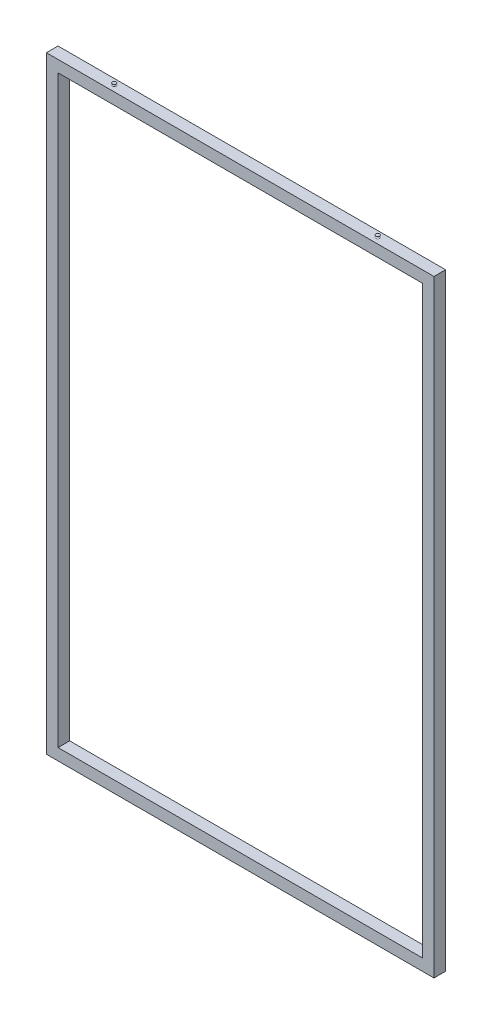
from build123d import *

# Parameters (mm, degrees)
SKETCH1_W           = 1000
SKETCH1_H           = 1567.75
SKETCH1_W_2         = 940
SKETCH1_H_2         = 1507.75
BOSS_EXTRUDE1_DEPTH = 15
SKETCH2_W           = 26
SKETCH2_H           = 26


with BuildPart() as part:
    # Sketch1 → Boss-Extrude1 (new body, symmetric)
    with BuildSketch(Plane.XY):
        Rectangle(SKETCH1_W, SKETCH1_H)
        Rectangle(SKETCH1_W_2, SKETCH1_H_2, mode=Mode.SUBTRACT)
    extrude(amount=BOSS_EXTRUDE1_DEPTH, both=True)

    # Cut-Sweep1: sweep along a path in Sketch4
    with BuildLine(Plane.XY) as cut_sweep1_path:
        Line((-485, 768.875), (-485, -768.875))
        Line((-485, -768.875), (485, -768.875))
        Line((485, -768.875), (485, 768.875))
        Line((485, 768.875), (-485, 768.875))
    # Sketch2 → Cut-Sweep1 (sweep, cut)
    with BuildSketch(Plane(origin=(0, 0, 0), x_dir=(0, 0, -1), z_dir=(1, 0, 0))):
        with Locations((0, 768.875)):
            Rectangle(SKETCH2_W, SKETCH2_H)
    sweep(path=cut_sweep1_path.line, transition=Transition.RIGHT, mode=Mode.SUBTRACT)

    # Sketch7 → Revolve1 (revolve)
    with BuildSketch(Plane.XY):
        with BuildLine():
            Line((-340, 783.875), (-340, 788.875))
            Line((-340, 788.875), (-345, 788.875))
            ThreePointArc((-345, 788.875), (-342.5, 786.375), (-345, 783.875))
            Line((-345, 783.875), (-340, 783.875))
        make_face()
    revolve1 = revolve(axis=Axis((-340, 795.104340353, 0), (0, 1, 0)))

    # Mirror1: Revolve1 across plane
    add(revolve1.mirror(Plane(origin=(0, 0, 0), x_dir=(0, 0, 1), z_dir=(1, 0, 0))))


solid = part.part
